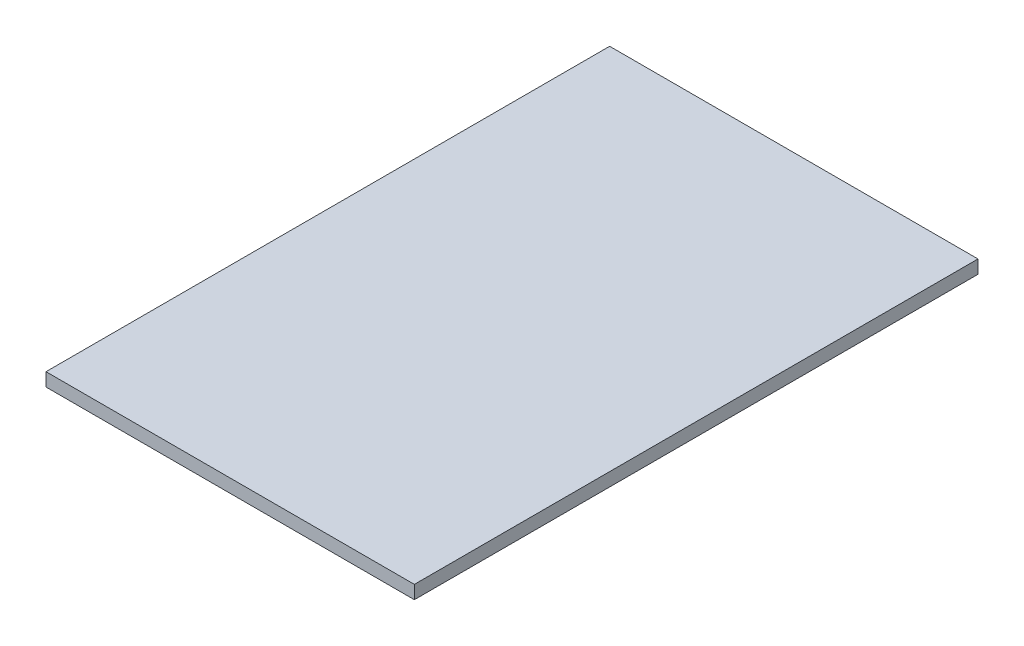
from build123d import *

# Parameters (mm, degrees)
SKETCH_1_W      = 498
SKETCH_1_H      = 762
EXTRUDE_1_DEPTH = 18


with BuildPart() as part:
    # Эскиз1 → Бобышка-Вытянуть1 (new body)
    with BuildSketch(Plane(origin=(0, 0, 0), x_dir=(1, 0, 0), z_dir=(0, 1, 0))):
        Rectangle(SKETCH_1_W, SKETCH_1_H)
    extrude(amount=EXTRUDE_1_DEPTH)


solid = part.part
